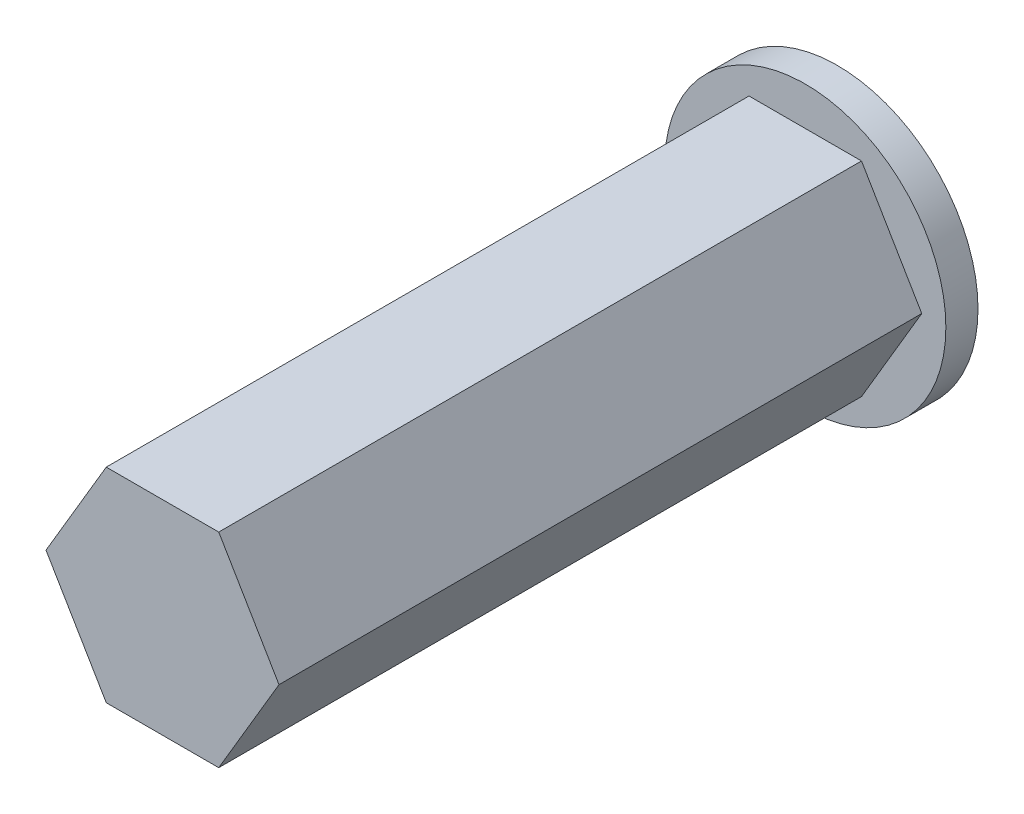
from build123d import *

# Parameters (mm, degrees)
SKETCH1_R           = 8.75
BOSS_EXTRUDE1_DEPTH = 2
BOSS_EXTRUDE2_DEPTH = 40


with BuildPart() as part:
    # Sketch1 → Boss-Extrude1 (new body)
    with BuildSketch(Plane.XY):
        Circle(SKETCH1_R)
    extrude(amount=BOSS_EXTRUDE1_DEPTH)

    # Sketch2 → Boss-Extrude2 (add)
    with BuildSketch(Plane.XY.offset(2)):
        Polygon((3.5, 6.35), (-3.5, 6.35), (-7.25, 0), (-3.5, -6.35), (3.5, -6.35), (7.25, 0), align=None)
    extrude(amount=BOSS_EXTRUDE2_DEPTH)


solid = part.part
